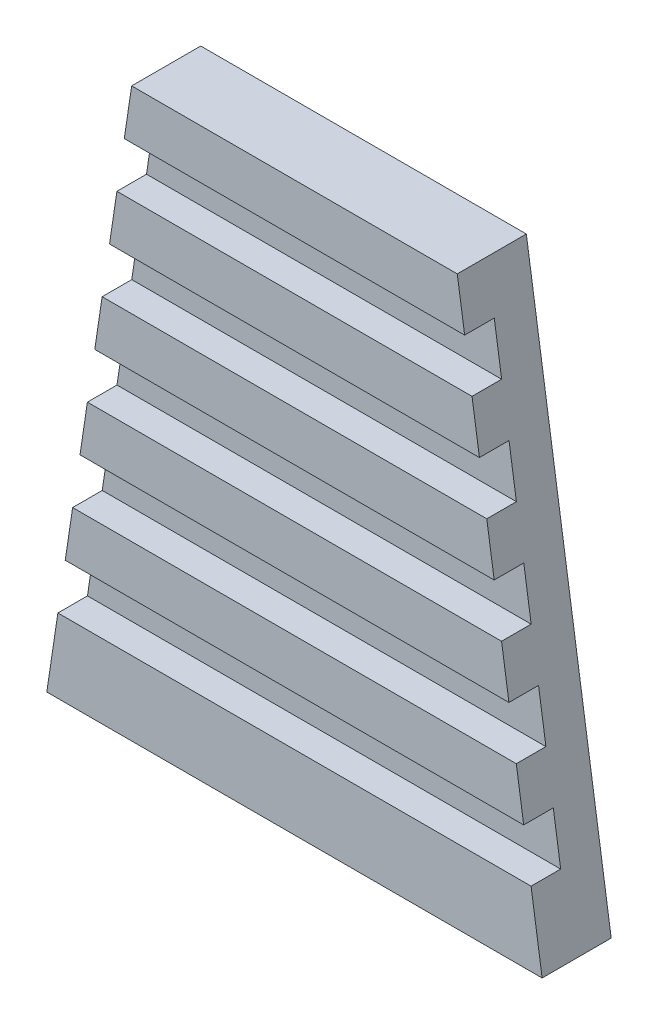
from build123d import *

# Parameters (mm, degrees)
EXTRUDE1_DEPTH = 4
EXTRUDE2_DEPTH = 3


with BuildPart() as part:
    # Sketch1 → Extrude1 (new body)
    with BuildSketch(Plane.XY):
        Polygon((-25.1, -28.75), (-16.5, 28.75), (16.5, 28.75), (25.1, -28.75), align=None)
    extrude(amount=EXTRUDE1_DEPTH)

    # Sketch2 → Extrude2 (add)
    with BuildSketch(Plane.XY.offset(4)):
        Polygon((-17.247826087, 23.75), (17.247826087, 23.75), (16.5, 28.75), (-16.5, 28.75), align=None)
        Polygon((-17.995652174, 18.75), (17.995652174, 18.75), (18.743478261, 13.75), (-18.743478261, 13.75), align=None)
        Polygon((-19.491304348, 8.75), (19.491304348, 8.75), (20.239130435, 3.75), (-20.239130435, 3.75), align=None)
        Polygon((-25.1, -28.75), (25.1, -28.75), (23.97826087, -21.25), (-23.97826087, -21.25), align=None)
        Polygon((-20.986956522, -1.25), (20.986956522, -1.25), (21.734782609, -6.25), (-21.734782609, -6.25), align=None)
        Polygon((-22.482608696, -11.25), (22.482608696, -11.25), (23.230434783, -16.25), (-23.230434783, -16.25), align=None)
    extrude(amount=EXTRUDE2_DEPTH)


solid = part.part
